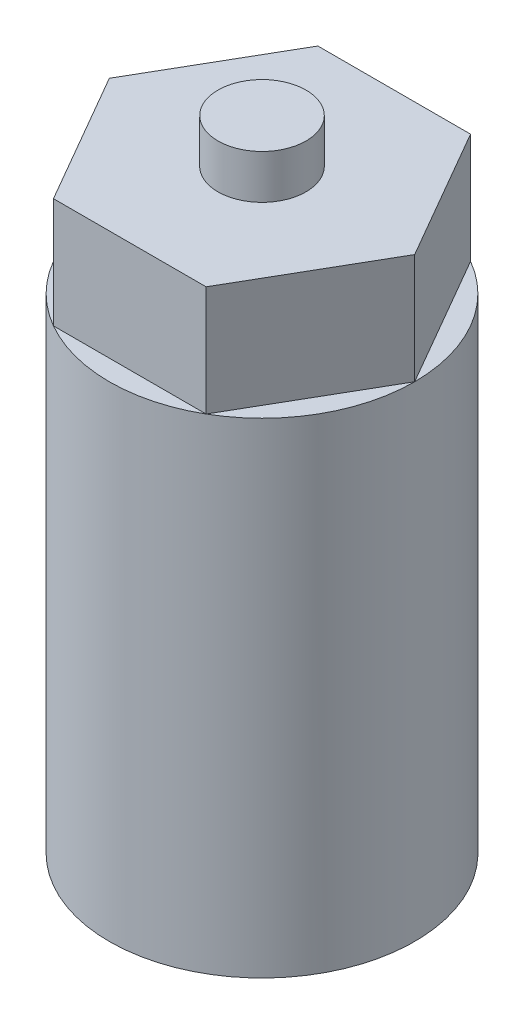
from build123d import *

# Parameters (mm, degrees)
BOSS_EXTRUDE1_DEPTH = 5
SKETCH1_3_R         = 2
BOSS_EXTRUDE2_DEPTH = 7
SKETCH2_R           = 6.92820323
BOSS_EXTRUDE3_DEPTH = 22


with BuildPart() as part:
    # Sketch1 → Boss-Extrude1 (new body)
    with BuildSketch(Plane(origin=(0, 0, 0), x_dir=(1, 0, 0), z_dir=(0, 1, 0))):
        Polygon((-6.92820323, 0), (-3.464101615, -6), (3.464101615, -6), (6.92820323, 0), (3.464101615, 6), (-3.464101615, 6), align=None)
    extrude(amount=BOSS_EXTRUDE1_DEPTH)

    # Sketch1_3 → Boss-Extrude2 (add)
    with BuildSketch(Plane(origin=(0, 0, 0), x_dir=(1, 0, 0), z_dir=(0, 1, 0))):
        Circle(SKETCH1_3_R)
    extrude(amount=BOSS_EXTRUDE2_DEPTH)

    # Sketch2 → Boss-Extrude3 (add)
    with BuildSketch(Plane.XZ):
        Circle(SKETCH2_R)
        with BuildLine():
            Line((-1.793739111, 2.65), (1.793739111, 2.65))
            ThreePointArc((1.793739111, 2.65), (0, -3.2), (-1.793739111, 2.65))
        make_face(mode=Mode.SUBTRACT)
    extrude(amount=BOSS_EXTRUDE3_DEPTH)


solid = part.part
